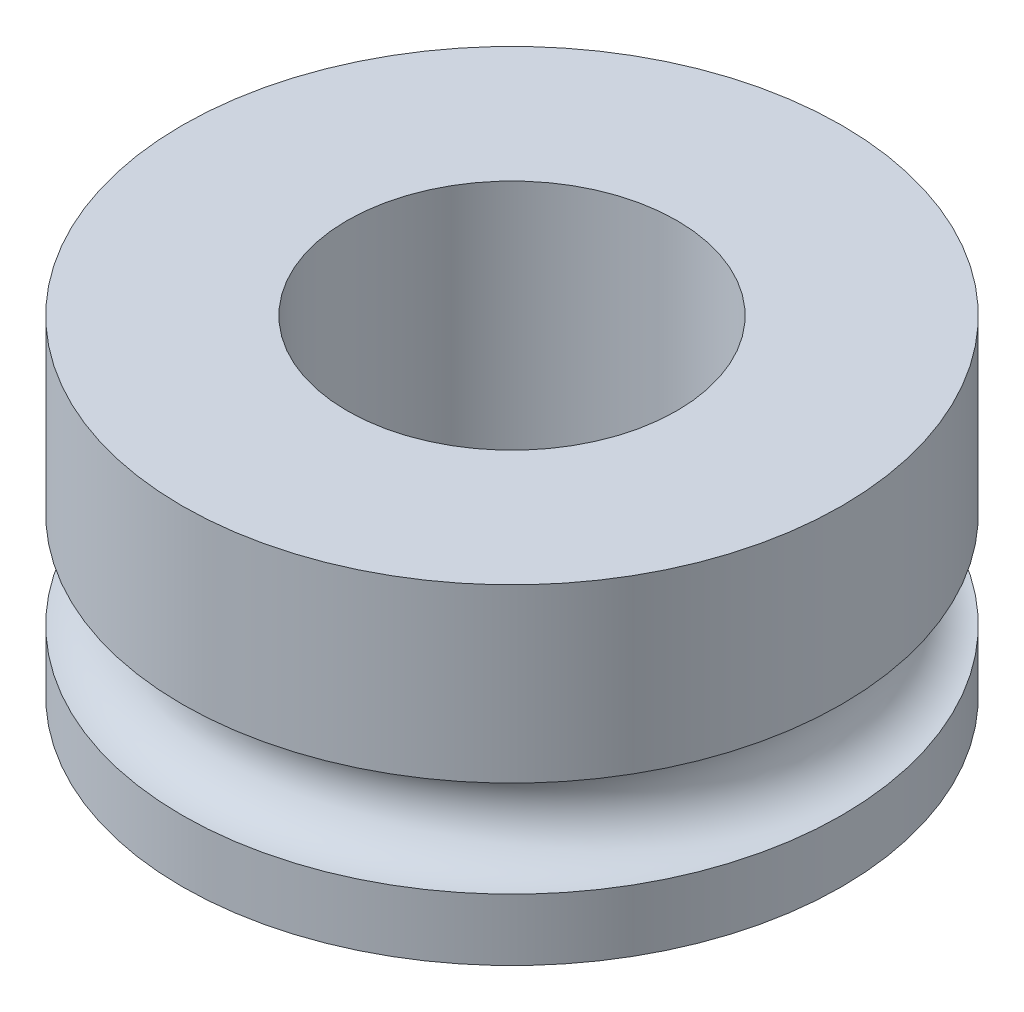
from build123d import *

# Parameters (mm, degrees)
SKETCH1_R           = 6
BOSS_EXTRUDE1_DEPTH = 6
SKETCH2_R           = 0.875
SKETCH4_R           = 3.000001976
CUT_EXTRUDE1_DEPTH  = 8


with BuildPart() as part:
    # Sketch1 → Boss-Extrude1 (new body)
    with BuildSketch(Plane(origin=(0, 0, 0), x_dir=(1, 0, 0), z_dir=(0, 1, 0))):
        Circle(SKETCH1_R)
    extrude(amount=BOSS_EXTRUDE1_DEPTH)

    # Sketch2 → Cut-Revolve1 (revolve, cut)
    with BuildSketch(Plane.XY):
        with Locations((6, 2)):
            Circle(SKETCH2_R)
    revolve(axis=Axis((0, 0, 0), (0, 1, 0)), mode=Mode.SUBTRACT)

    # Sketch4 → Cut-Extrude1 (cut)
    with BuildSketch(Plane(origin=(0, 6, 0), x_dir=(1, 0, 0), z_dir=(0, 1, 0))):
        Circle(SKETCH4_R)
    extrude(amount=-CUT_EXTRUDE1_DEPTH, mode=Mode.SUBTRACT)


solid = part.part
